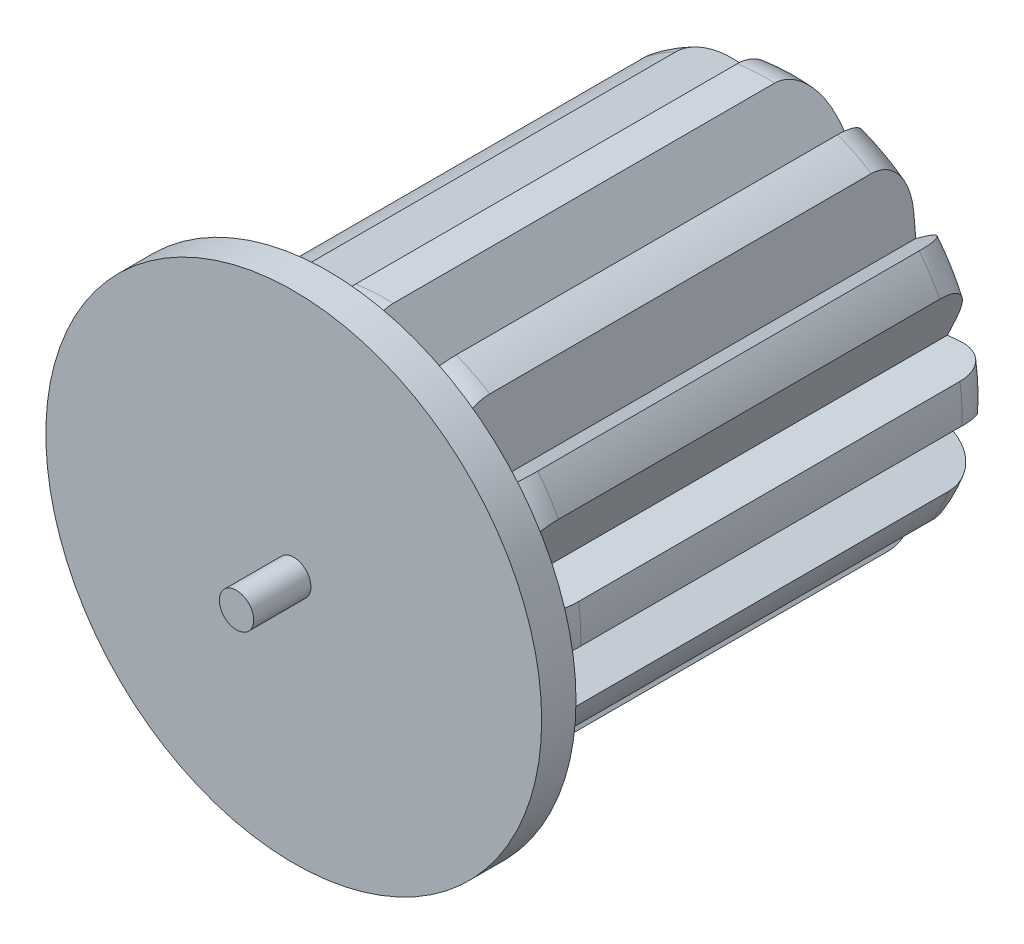
from build123d import *

# Parameters (mm, degrees)
SKETCH1_R           = 102.5
BOSS_EXTRUDE1_DEPTH = 250
FILLET1_R           = 30
FILLET2_R           = 20
CUT_EXTRUDE1_DEPTH  = 250
CIRPATTERN1_COUNT   = 12
SKETCH3_R           = 130
BOSS_EXTRUDE2_DEPTH = 18
SKETCH4_R           = 9
BOSS_EXTRUDE3_DEPTH = 30


with BuildPart() as part:
    # Sketch1 → Boss-Extrude1 (new body)
    with BuildSketch(Plane.XY):
        Circle(SKETCH1_R)
    extrude(amount=BOSS_EXTRUDE1_DEPTH)

    # Fillet1
    fillet1_edges = [part.edges().sort_by_distance(p)[0] for p in [
        (-102.5, 0, 250),
    ]]
    fillet(fillet1_edges, radius=FILLET1_R)

    # Fillet2
    fillet2_edges = [part.edges().sort_by_distance(p)[0] for p in [
        (-102.5, 0, 0),
    ]]
    fillet(fillet2_edges, radius=FILLET2_R)

    # Sketch2 → Cut-Extrude1 (cut)
    with BuildSketch(Plane.XY.offset(250)):
        Polygon((-114.285936497, 121.874338978), (-13.218490211, 74.745814784), (-22.937714159, 185.837052861), align=None)
    cut_extrude1 = extrude(amount=-CUT_EXTRUDE1_DEPTH, mode=Mode.SUBTRACT)

    # CirPattern1: Cut-Extrude1 ×12 about axis
    cirpattern1_axis = Axis((0, 0, 0), (0, 0, 1))
    for i in range(1, CIRPATTERN1_COUNT):
        add(cut_extrude1.rotate(cirpattern1_axis, i * 360 / CIRPATTERN1_COUNT), mode=Mode.SUBTRACT)

    # Sketch3 → Boss-Extrude2 (add)
    with BuildSketch(Plane.XY.offset(250)):
        Circle(SKETCH3_R)
    extrude(amount=BOSS_EXTRUDE2_DEPTH)

    # Sketch4 → Boss-Extrude3 (add)
    with BuildSketch(Plane.XY.offset(268)):
        Circle(SKETCH4_R)
    extrude(amount=BOSS_EXTRUDE3_DEPTH)


solid = part.part
